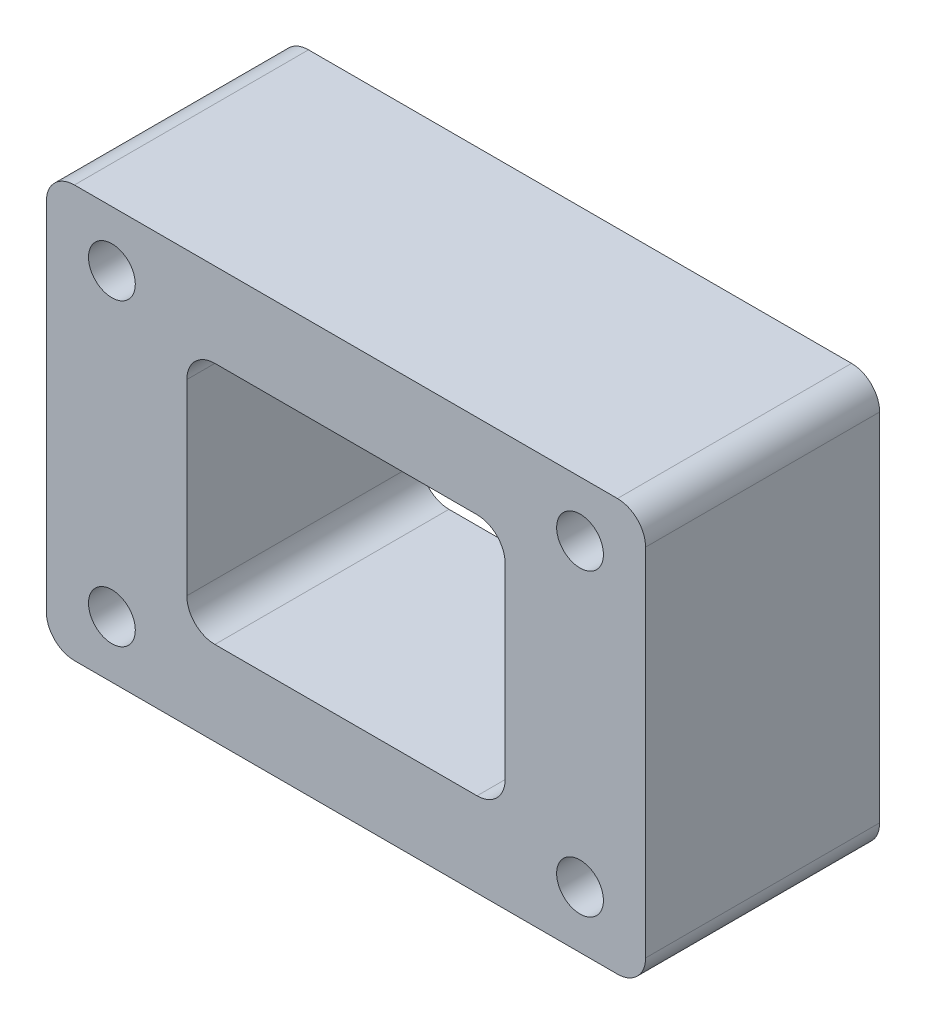
from build123d import *

# Parameters (mm, degrees)
SKETCH_1_W      = 64
SKETCH_1_H      = 44
SKETCH_1_R      = 2.5
SKETCH_1_W_2    = 34
SKETCH_1_H_2    = 26
EXTRUDE_1_DEPTH = 25
FILLET_1_R      = 3


with BuildPart() as part:
    # 草图1 → 凸台-拉伸1 (new body)
    with BuildSketch(Plane.XY):
        Rectangle(SKETCH_1_W, SKETCH_1_H)
        with Locations((-25, 16.06779661)):
            Circle(SKETCH_1_R, mode=Mode.SUBTRACT)
        with Locations((-25, -15.93220339)):
            Circle(SKETCH_1_R, mode=Mode.SUBTRACT)
        with Locations((25, -15.93220339)):
            Circle(SKETCH_1_R, mode=Mode.SUBTRACT)
        with Locations((25, 16.06779661)):
            Circle(SKETCH_1_R, mode=Mode.SUBTRACT)
        Rectangle(SKETCH_1_W_2, SKETCH_1_H_2, mode=Mode.SUBTRACT)
    extrude(amount=EXTRUDE_1_DEPTH)

    # 圆角1
    fillet_1_edges = [part.edges().sort_by_distance(p)[0] for p in [
        (17, -13, 12.5),
        (17, 13, 12.5),
        (-17, 13, 12.5),
        (-17, -13, 12.5),
        (32, -22, 12.5),
        (-32, -22, 12.5),
        (-32, 22, 12.5),
        (32, 22, 12.5),
    ]]
    fillet(fillet_1_edges, radius=FILLET_1_R)


solid = part.part
